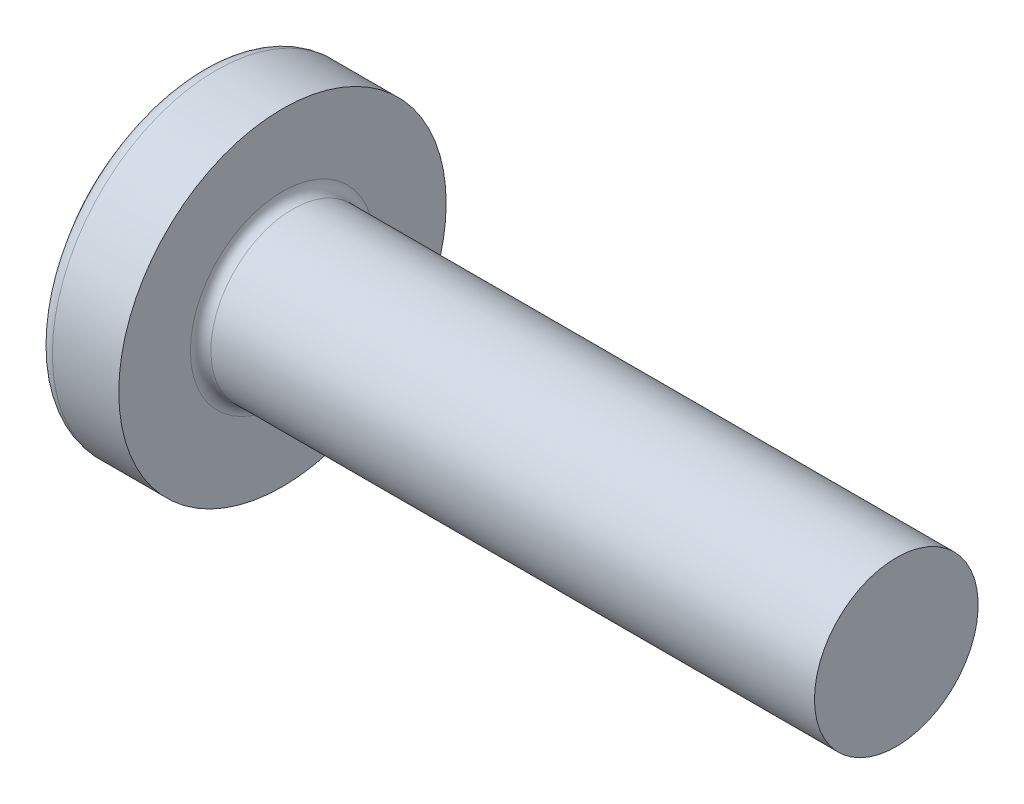
from build123d import *

# Parameters (mm, degrees)
FILLET1_R    = 0.1
SKETCH3_W    = 0.48
SKETCH3_H    = 1.6
SKETCH4_W    = 0.48
SKETCH4_H    = 0.702553256
RECPAT_COUNT = 2
RECPAT_ANGLE = 90


with BuildPart() as part:
    # BodySke → Base-Revolve (revolve)
    with BuildSketch(Plane.XY):
        with BuildLine():
            Line((1.3, 0.8), (1.3, 1.6))
            Line((1.3, 1.6), (0.650675799, 1.6))
            ThreePointArc((0.650675799, 1.6), (0.585036553, 1.584875829), (0.532633829, 1.542553191))
            ThreePointArc((0.532633829, 1.542553191), (0.136907172, 0.815960959), (0, 0))
            Line((0, 0), (7.3, 0))
            Line((7.3, 0), (7.3, 0.8))
            Line((7.3, 0.8), (1.3, 0.8))
        make_face()
    revolve(axis=Axis((-25.4, 0, 0), (1, 0, 0)))

    # Fillet1
    fillet1_edges = [part.edges().sort_by_distance(p)[0] for p in [
        (1.3, -0.8, 0),
    ]]
    fillet(fillet1_edges, radius=FILLET1_R)

    # Sketch3 → Recess section 0
    with BuildSketch(Plane(origin=(0, 0, 0), x_dir=(0, 0, -1), z_dir=(1, 0, 0))):
        Rectangle(SKETCH3_W, SKETCH3_H)
    # Sketch4 → Recess section 1
    with BuildSketch(Plane(origin=(0.9, 0, 0), x_dir=(0, 0, -1), z_dir=(1, 0, 0))):
        Rectangle(SKETCH4_W, SKETCH4_H)
    recess = loft(mode=Mode.SUBTRACT)

    # RecPat: Recess ×2 about axis
    recpat_axis = Axis((0, 0, 0), (1, 0, 0))
    for i in range(1, RECPAT_COUNT):
        add(recess.rotate(recpat_axis, i * RECPAT_ANGLE / (RECPAT_COUNT - 1)), mode=Mode.SUBTRACT)

    # RecCorSke → RecessCore (revolve, cut)
    with BuildSketch(Plane.XY):
        Polygon((0, 0), (0, 0.418434131), (0.9, 0.3555), (1.015508952, 0), align=None)
    revolve(axis=Axis((-3.175, 0, 0), (1, 0, 0)), mode=Mode.SUBTRACT)


solid = part.part
